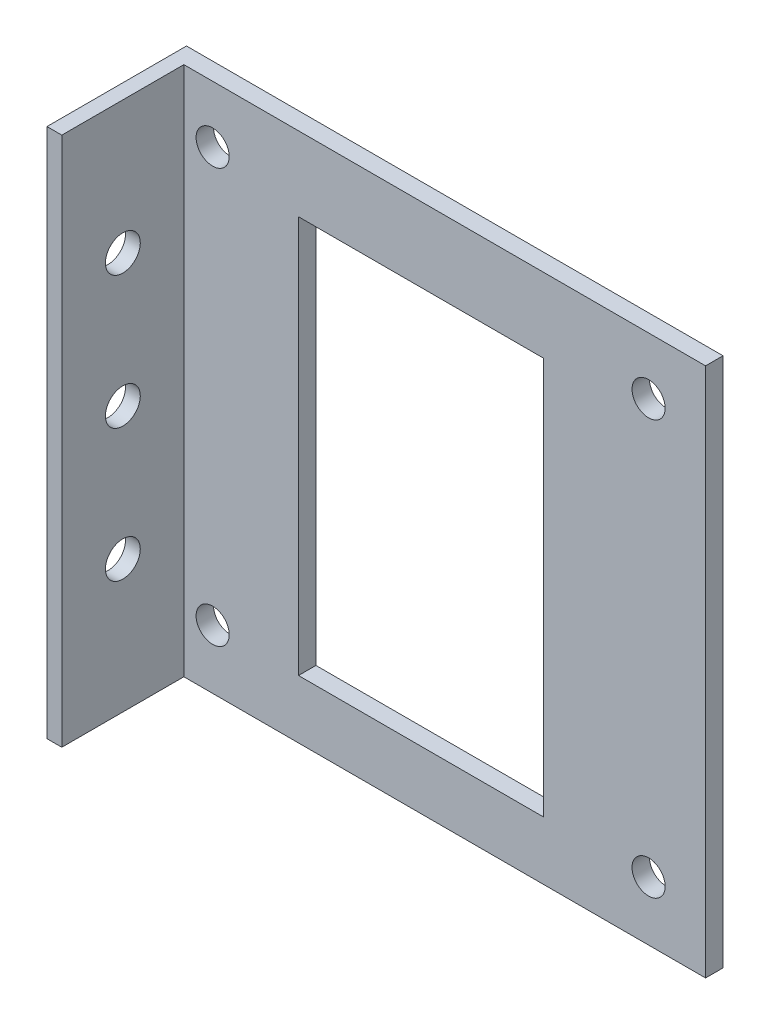
from build123d import *

# Parameters (mm, degrees)
SKETCH2_W           = 78.150454931
SKETCH2_H           = 77.221988429
SKETCH2_R           = 2.413
SKETCH2_W_2         = 35.652738644
SKETCH2_H_2         = 57.874285637
BOSS_EXTRUDE1_DEPTH = 2.54
SKETCH3_W           = 2.159598277
SKETCH3_H           = 77.221988429
BOSS_EXTRUDE2_DEPTH = 17.78
SKETCH5_R           = 2.54
CUT_EXTRUDE2_DEPTH  = 17.78


with BuildPart() as part:
    # Sketch2 → Boss-Extrude1 (new body)
    with BuildSketch(Plane.XY):
        with Locations((6.487490533, -7.63692736)):
            Rectangle(SKETCH2_W, SKETCH2_H)
        with Locations((-26.23773696, 22.67645588)):
            Circle(SKETCH2_R, mode=Mode.SUBTRACT)
        with Locations((37.26226304, 22.67645588)):
            Circle(SKETCH2_R, mode=Mode.SUBTRACT)
        with Locations((37.26226304, -37.64854412)):
            Circle(SKETCH2_R, mode=Mode.SUBTRACT)
        with Locations((-26.23773696, -37.64854412)):
            Circle(SKETCH2_R, mode=Mode.SUBTRACT)
        with Locations((4.092128919, -8.801242849)):
            Rectangle(SKETCH2_W_2, SKETCH2_H_2, mode=Mode.SUBTRACT)
    extrude(amount=BOSS_EXTRUDE1_DEPTH)

    # Sketch3 → Boss-Extrude2 (add)
    with BuildSketch(Plane.XY.offset(2.54)):
        with Locations((-31.507937795, -7.63692736)):
            Rectangle(SKETCH3_W, SKETCH3_H)
    extrude(amount=BOSS_EXTRUDE2_DEPTH)

    # Sketch5 → Cut-Extrude2 (cut)
    with BuildSketch(Plane(origin=(-30.428138656, 0, 0), x_dir=(0, 0, -1), z_dir=(1, 0, 0))):
        with Locations((-11.43, -7.636927359)):
            Circle(SKETCH5_R)
        with Locations((-11.43, 11.668569748)):
            Circle(SKETCH5_R)
        with Locations((-11.43, -26.942424466)):
            Circle(SKETCH5_R)
    extrude(amount=-CUT_EXTRUDE2_DEPTH, mode=Mode.SUBTRACT)


solid = part.part
